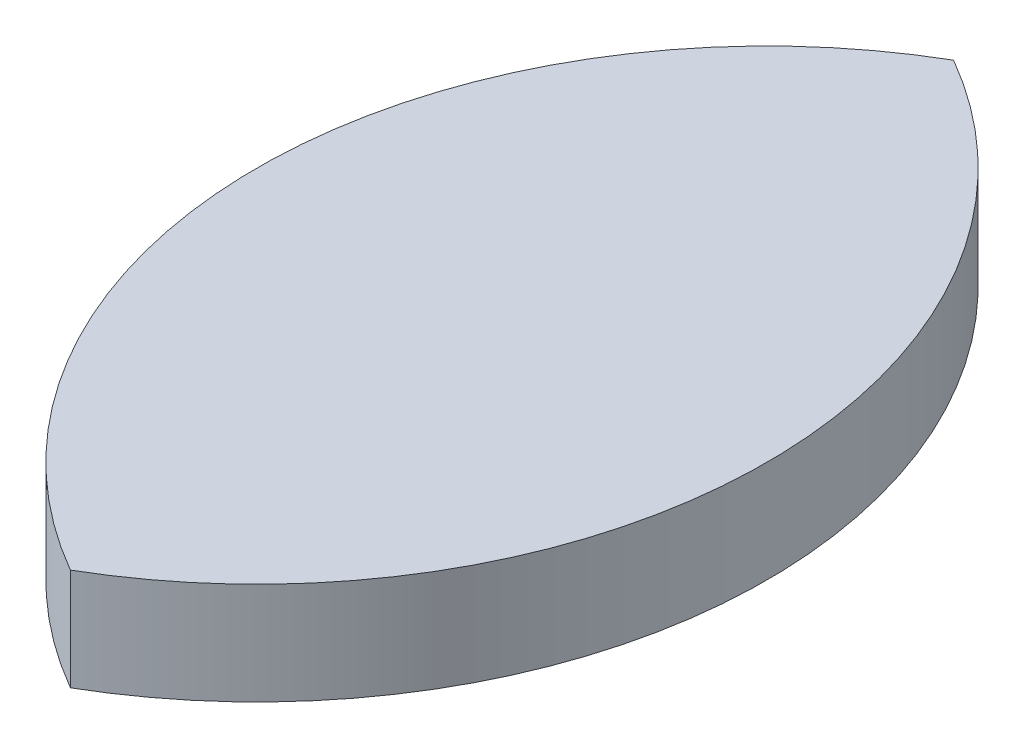
from build123d import *

# Parameters (mm, degrees)
BOSS_EXTRUDE2_DEPTH = 10


with BuildPart() as part:
    # Sketch1 → Boss-Extrude2 (new body)
    with BuildSketch(Plane(origin=(0, 0, 0), x_dir=(1, 0, 0), z_dir=(0, 1, 0))):
        with BuildLine():
            ThreePointArc((25, -43.301270189), (50, 0), (25, 43.301270189))
            ThreePointArc((25, 43.301270189), (0, 0), (25, -43.301270189))
        make_face()
    extrude(amount=BOSS_EXTRUDE2_DEPTH)


solid = part.part
